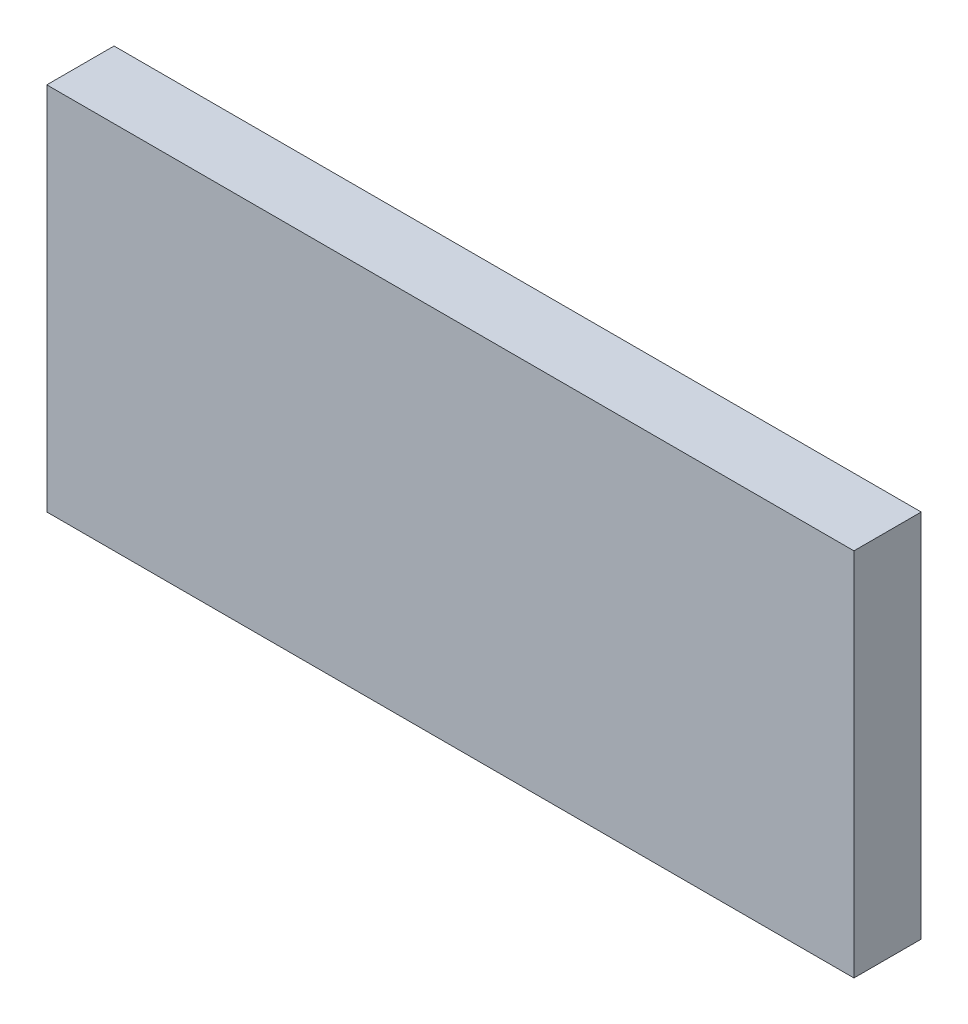
from build123d import *

# Parameters (mm, degrees)
SKETCH_1_W      = 120
SKETCH_1_H      = 55
EXTRUDE_1_DEPTH = 10


with BuildPart() as part:
    # 草圖1 → 填料-伸長1 (new body)
    with BuildSketch(Plane.XY):
        Rectangle(SKETCH_1_W, SKETCH_1_H)
    extrude(amount=EXTRUDE_1_DEPTH)


solid = part.part
